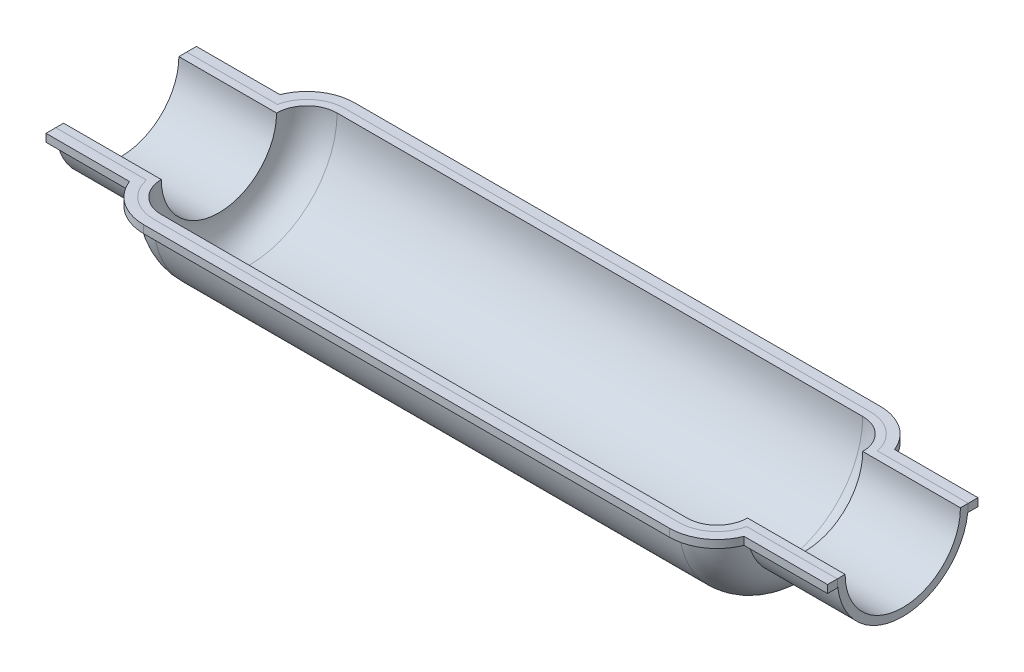
from build123d import *

# Parameters (mm, degrees)
REVOLVE1_ANGLE        = 180
BOSS_EXTRUDE2_DEPTH   = 4
BOSS_EXTRUDE2_2_DEPTH = 4


with BuildPart() as part:
    # Sketch1 → Revolve1 (revolve)
    with BuildSketch(Plane(origin=(0, 0, 0), x_dir=(1, 0, 0), z_dir=(0, 1, 0))):
        with BuildLine():
            Line((-200, 29.5), (-150, 29.5))
            ThreePointArc((-150, 29.5), (-145.460155108, 40.460155108), (-134.5, 45))
            Line((-134.5, 45), (134.5, 45))
            ThreePointArc((134.5, 45), (145.460155108, 40.460155108), (150, 29.5))
            Line((150, 29.5), (200, 29.5))
            Line((200, 29.5), (200, 33.5))
            Line((200, 33.5), (153.585334684, 33.5))
            ThreePointArc((153.585334684, 33.5), (146.793290853, 44.636875503), (134.5, 49))
            Line((134.5, 49), (-134.5, 49))
            ThreePointArc((-134.5, 49), (-146.793290853, 44.636875503), (-153.585334684, 33.5))
            Line((-153.585334684, 33.5), (-200, 33.5))
            Line((-200, 33.5), (-200, 29.5))
        make_face()
    revolve(axis=Axis((0, 0, 0), (-1, 0, 0)), revolution_arc=REVOLVE1_ANGLE)


with BuildPart() as body_2:
    # Sketch3 → Boss-Extrude2 (new body)
    with BuildSketch(Plane(origin=(0, 0, 0), x_dir=(1, 0, 0), z_dir=(0, 1, 0))):
        with BuildLine():
            Line((200, 33.5), (153.585334684, 33.5))
            ThreePointArc((153.585334684, 33.5), (146.793290853, 44.636875503), (134.5, 49))
            Line((134.5, 49), (-134.5, 49))
            ThreePointArc((-134.5, 49), (-146.793290853, 44.636875503), (-153.585334684, 33.5))
            Line((-153.585334684, 33.5), (-200, 33.5))
            Line((-200, 33.5), (-200, 38.5))
            Line((-200, 38.5), (-157.28705773, 38.5))
            ThreePointArc((-157.28705773, 38.5), (-148.27951378, 49.75771458), (-134.5, 54))
            Line((-134.5, 54), (134.5, 54))
            ThreePointArc((134.5, 54), (148.27951378, 49.75771458), (157.28705773, 38.5))
            Line((157.28705773, 38.5), (200, 38.5))
            Line((200, 38.5), (200, 33.5))
        make_face()
    extrude(amount=-BOSS_EXTRUDE2_DEPTH)


with BuildPart() as body_3:
    # Sketch3 → Boss-Extrude2 2 (new body)
    with BuildSketch(Plane(origin=(0, 0, 0), x_dir=(1, 0, 0), z_dir=(0, 1, 0))):
        with BuildLine():
            Line((200, -38.5), (200, -33.5))
            Line((200, -33.5), (153.585334684, -33.5))
            ThreePointArc((153.585334684, -33.5), (146.793290853, -44.636875503), (134.5, -49))
            Line((134.5, -49), (-134.5, -49))
            ThreePointArc((-134.5, -49), (-146.793290853, -44.636875503), (-153.585334684, -33.5))
            Line((-153.585334684, -33.5), (-200, -33.5))
            Line((-200, -33.5), (-200, -38.5))
            Line((-200, -38.5), (-157.28705773, -38.5))
            ThreePointArc((-157.28705773, -38.5), (-148.27951378, -49.75771458), (-134.5, -54))
            Line((-134.5, -54), (134.5, -54))
            ThreePointArc((134.5, -54), (148.27951378, -49.75771458), (157.28705773, -38.5))
            Line((157.28705773, -38.5), (200, -38.5))
        make_face()
    extrude(amount=-BOSS_EXTRUDE2_2_DEPTH)


solid = Compound([part.part, body_2.part, body_3.part])
